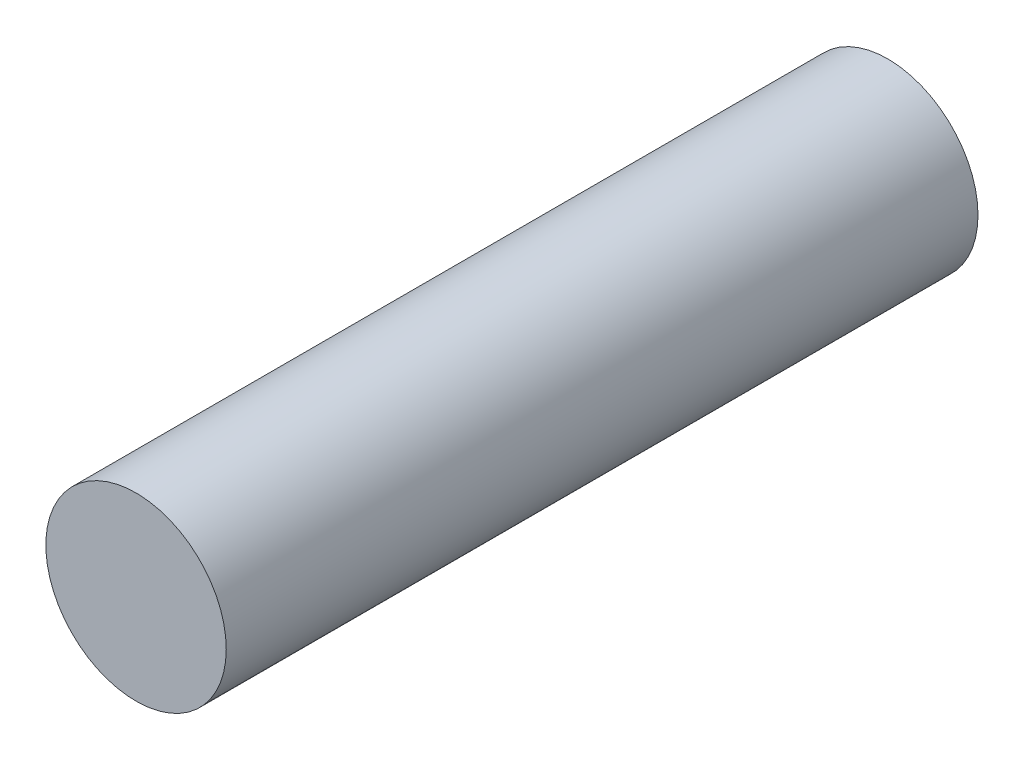
from build123d import *

# Parameters (mm, degrees)
SKETCH1_R           = 3
BOSS_EXTRUDE1_DEPTH = 25


with BuildPart() as part:
    # Sketch1 → Boss-Extrude1 (new body)
    with BuildSketch(Plane.XY):
        Circle(SKETCH1_R)
    extrude(amount=BOSS_EXTRUDE1_DEPTH)


solid = part.part
